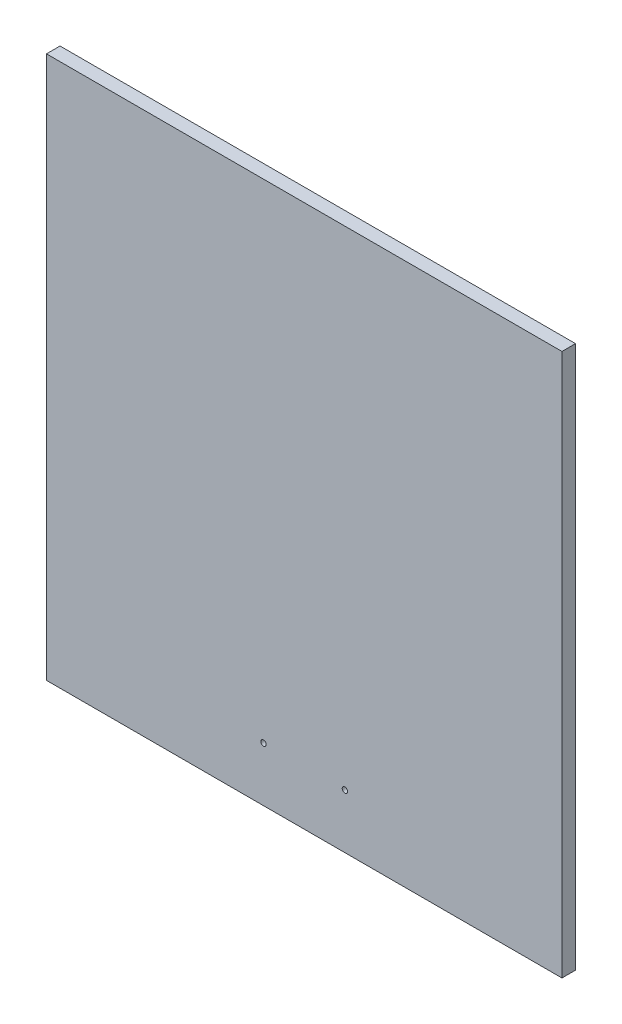
from build123d import *

# Parameters (mm, degrees)
CROQUIS1_W              = 190
CROQUIS1_H              = 200
SALIENTE_EXTRUIR1_DEPTH = 5
CROQUIS2_R              = 1
CORTAR_EXTRUIR1_DEPTH   = 10


with BuildPart() as part:
    # Croquis1 → Saliente-Extruir1 (new body)
    with BuildSketch(Plane.XY):
        Rectangle(CROQUIS1_W, CROQUIS1_H)
    extrude(amount=SALIENTE_EXTRUIR1_DEPTH)

    # Croquis2 → Cortar-Extruir1 (cut)
    with BuildSketch(Plane.XY.offset(5)):
        with Locations((-15, -80)):
            Circle(CROQUIS2_R)
        with Locations((15, -80)):
            Circle(CROQUIS2_R)
    extrude(amount=-CORTAR_EXTRUIR1_DEPTH, mode=Mode.SUBTRACT)


solid = part.part
